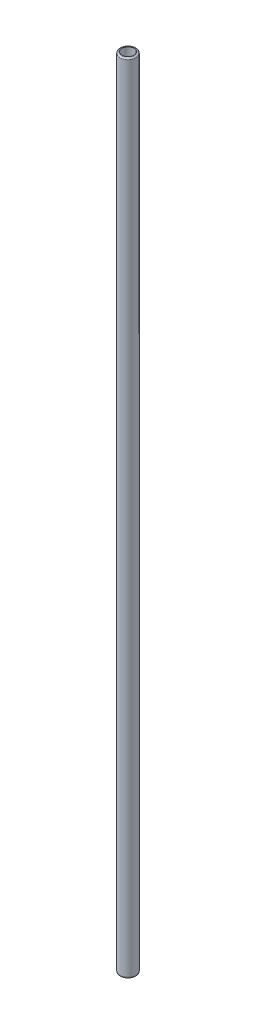
from build123d import *

# Parameters (mm, degrees)
SKETCH1_R           = 6
SKETCH1_R_2         = 4.5
BOSS_EXTRUDE1_DEPTH = 600
FILLET3_R           = 1
FILLET4_R           = 1


with BuildPart() as part:
    # Sketch1 → Boss-Extrude1 (new body)
    with BuildSketch(Plane(origin=(0, 0, 0), x_dir=(1, 0, 0), z_dir=(0, 1, 0))):
        Circle(SKETCH1_R)
        Circle(SKETCH1_R_2, mode=Mode.SUBTRACT)
    extrude(amount=BOSS_EXTRUDE1_DEPTH)

    # Fillet3
    fillet3_edges = [part.edges().sort_by_distance(p)[0] for p in [
        (-6, 0, 0),
    ]]
    fillet(fillet3_edges, radius=FILLET3_R)

    # Fillet4
    fillet4_edges = [part.edges().sort_by_distance(p)[0] for p in [
        (-6, 600, 0),
    ]]
    fillet(fillet4_edges, radius=FILLET4_R)


solid = part.part
